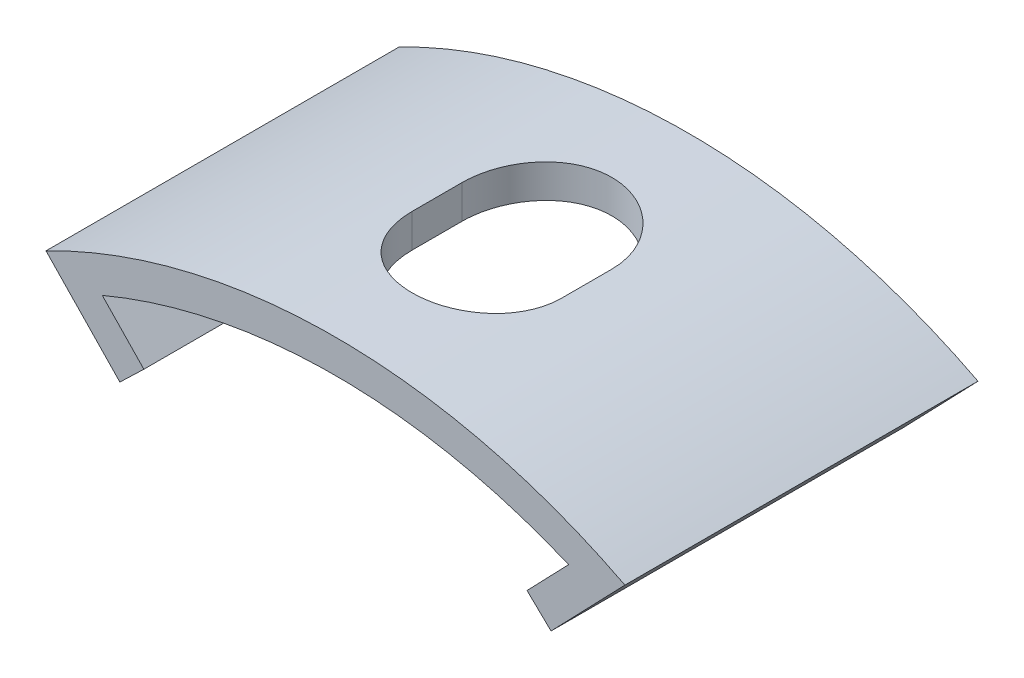
from build123d import *

# Parameters (mm, degrees)
EXTRU_MINCE1_DEPTH      = 5.3
ENL_V_MAT_EXTRU_1_DEPTH = 5.5


with BuildPart() as part:
    # Esquisse1 → Extru.-Mince1 (new body, symmetric)
    with BuildSketch(Plane.XY):
        with BuildLine():
            Line((5.751633114, 15.286366412), (7, 16.583123952))
            ThreePointArc((7, 16.583123952), (0, 18), (-7, 16.583123952))
            Line((-7, 16.583123952), (-5.751633114, 15.286366412))
            Line((-5.751633114, 15.286366412), (-6.47205397, 14.592829253))
            Line((-6.47205397, 14.592829253), (-8.689690241, 16.896428129))
            ThreePointArc((-8.689690241, 16.896428129), (0, 19), (8.689690241, 16.896428129))
            Line((8.689690241, 16.896428129), (6.47205397, 14.592829253))
            Line((6.47205397, 14.592829253), (5.751633114, 15.286366412))
        make_face()
    extrude(amount=EXTRU_MINCE1_DEPTH, both=True)

    # Esquisse2 → Enlèv. mat.-Extru.1 (cut, symmetric)
    with BuildSketch(Plane(origin=(0, 18, 0), x_dir=(-1, 0, 0), z_dir=(0, 1, 0))):
        with BuildLine():
            Line((-2.25, 0.75), (-2.25, -0.75))
            ThreePointArc((-2.25, -0.75), (0, -3), (2.25, -0.75))
            Line((2.25, -0.75), (2.25, 0.75))
            ThreePointArc((2.25, 0.75), (0, 3), (-2.25, 0.75))
        make_face()
    extrude(amount=ENL_V_MAT_EXTRU_1_DEPTH, both=True, mode=Mode.SUBTRACT)


solid = part.part
